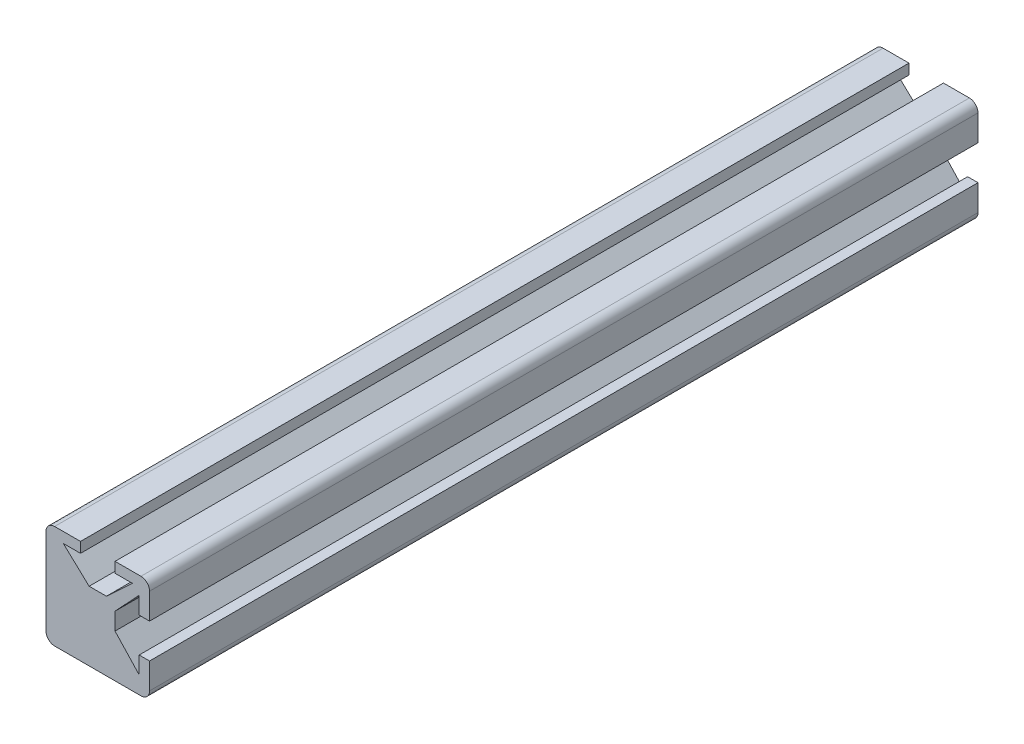
from build123d import *

# Parameters (mm, degrees)
EXTRUSION1_DEPTH             = 48
ENL_V_MAT_EXTRU_1_DEPTH      = 97.374270425
R_P_TITION_CIRCULAIRE1_COUNT = 2
R_P_TITION_CIRCULAIRE1_ANGLE = 90


with BuildPart() as part:
    # Esquisse1 → Extrusion1 (new, symmetric)
    with BuildSketch(Plane.XY):
        with BuildLine():
            Line((-6, 5), (-6, -5))
            ThreePointArc((-6, -5), (-5.707106781, -5.707106781), (-5, -6))
            Line((-5, -6), (5, -6))
            ThreePointArc((5, -6), (5.707106781, -5.707106781), (6, -5))
            Line((6, -5), (6, 5))
            ThreePointArc((6, 5), (5.707106781, 5.707106781), (5, 6))
            Line((5, 6), (-5, 6))
            ThreePointArc((-5, 6), (-5.707106781, 5.707106781), (-6, 5))
        make_face()
    extrude(amount=EXTRUSION1_DEPTH, both=True)

    # Esquisse3 → Enlèv. mat.-Extru.1 (cut, through all)
    with BuildSketch(Plane.XY.offset(48)):
        Polygon((6, 2), (4.8, 2), (4.8, 4), (2, 1), (2, -1), (4.8, -4), (4.8, -2), (6, -2), align=None)
    enl_v_mat_extru_1 = extrude(amount=-ENL_V_MAT_EXTRU_1_DEPTH, mode=Mode.SUBTRACT)

    # Répétition circulaire1: Enlèv. mat.-Extru.1 ×2 about axis
    r_p_tition_circulaire1_axis = Axis((0, 0, -1), (0, 0, 1))
    for i in range(1, R_P_TITION_CIRCULAIRE1_COUNT):
        add(enl_v_mat_extru_1.rotate(r_p_tition_circulaire1_axis, i * R_P_TITION_CIRCULAIRE1_ANGLE / (R_P_TITION_CIRCULAIRE1_COUNT - 1)), mode=Mode.SUBTRACT)


solid = part.part
